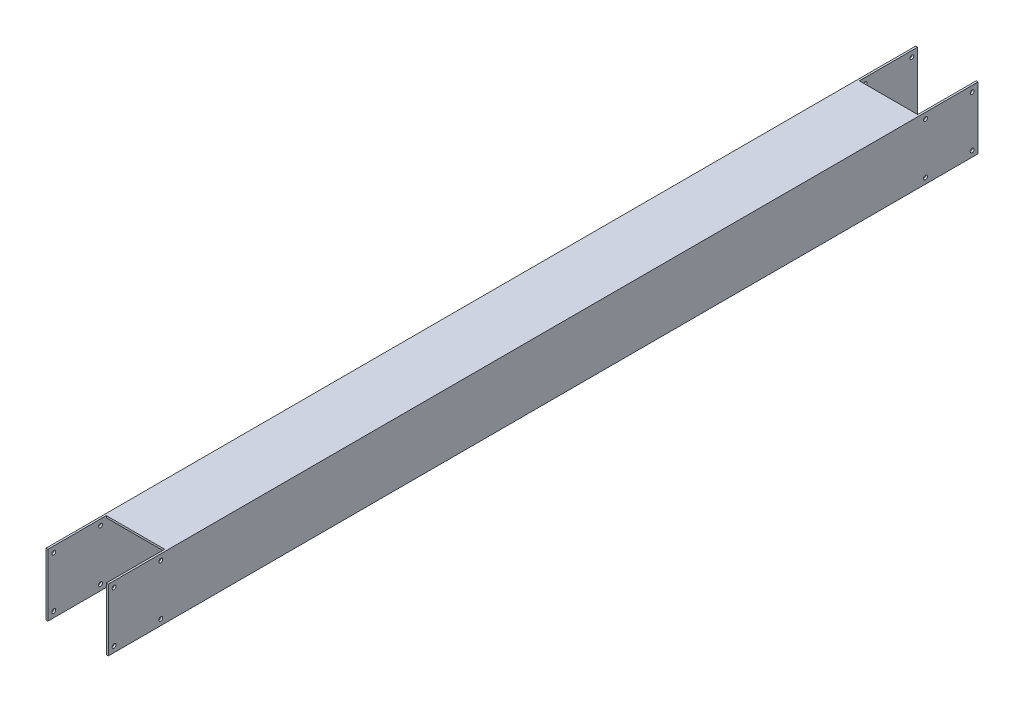
from build123d import *

# Parameters (mm, degrees)
SKETCH1_W           = 320
SKETCH1_H           = 320
SKETCH1_W_2         = 300
SKETCH1_H_2         = 300
BOSS_EXTRUDE1_DEPTH = 4470
SKETCH2_W           = 300
SKETCH2_H           = 369.06637508
CUT_EXTRUDE1_DEPTH  = 300
SKETCH3_R           = 10
CUT_EXTRUDE2_DEPTH  = 321


with BuildPart() as part:
    # Sketch1 → Boss-Extrude1 (new body)
    with BuildSketch(Plane.XY):
        Rectangle(SKETCH1_W, SKETCH1_H)
        Rectangle(SKETCH1_W_2, SKETCH1_H_2, mode=Mode.SUBTRACT)
    extrude(amount=BOSS_EXTRUDE1_DEPTH)

    # Sketch2 → Cut-Extrude1 (cut)
    with BuildSketch(Plane.XY.offset(4470)):
        Rectangle(SKETCH2_W, SKETCH2_H)
    cut_extrude1 = extrude(amount=-CUT_EXTRUDE1_DEPTH, mode=Mode.SUBTRACT)

    # Sketch3 → Cut-Extrude2 (cut, through all)
    with BuildSketch(Plane(origin=(160, 0, 0), x_dir=(0, 0, -1), z_dir=(1, 0, 0))):
        with Locations((-4440, 130)):
            Circle(SKETCH3_R)
        with Locations((-4200, 130)):
            Circle(SKETCH3_R)
        with Locations((-4200, -130)):
            Circle(SKETCH3_R)
        with Locations((-4440, -130)):
            Circle(SKETCH3_R)
    cut_extrude2 = extrude(amount=-CUT_EXTRUDE2_DEPTH, mode=Mode.SUBTRACT)

    # Mirror1: Cut-Extrude1, Cut-Extrude2 across plane
    add(cut_extrude1.mirror(Plane(origin=(0, 0, 2235), x_dir=(1, 0, 0), z_dir=(0, 0, -1))), mode=Mode.SUBTRACT)
    add(cut_extrude2.mirror(Plane(origin=(0, 0, 2235), x_dir=(1, 0, 0), z_dir=(0, 0, -1))), mode=Mode.SUBTRACT)


solid = part.part
